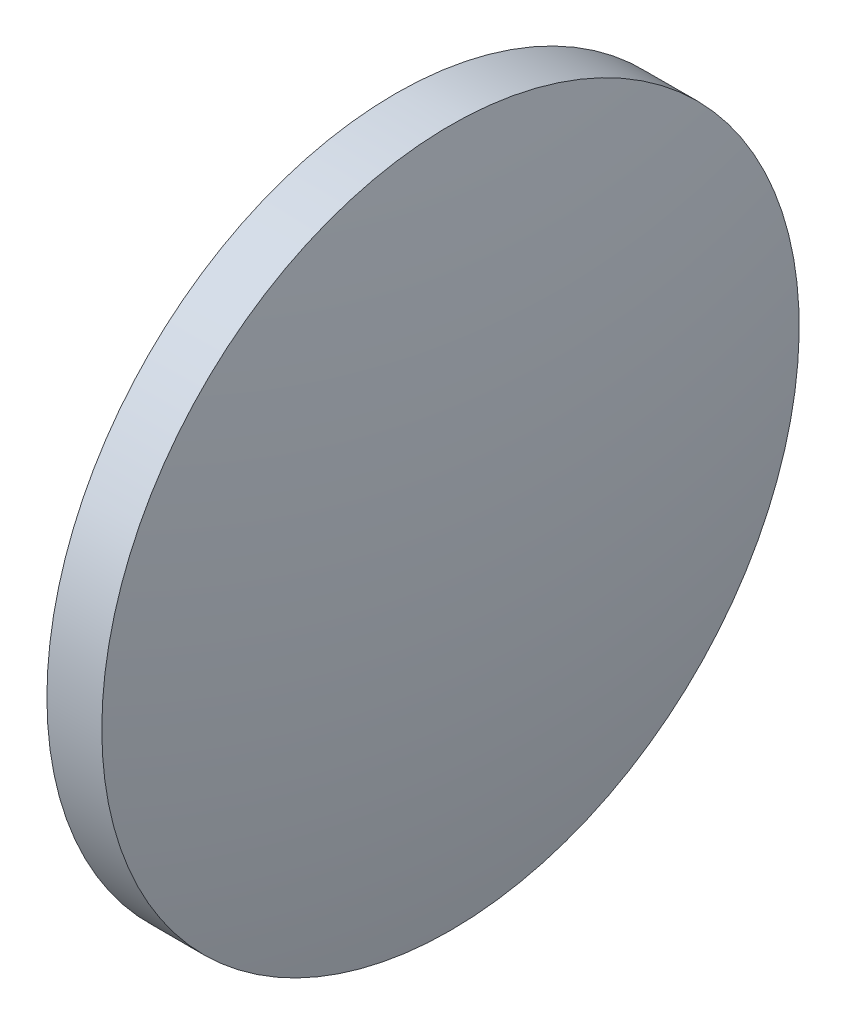
from build123d import *

# Parameters (mm, degrees)
SKETCH_1_ONE_SIDE_W = 1.999342857
SKETCH_1_ONE_SIDE_H = 12.7


with BuildPart() as part:
    # 草图1 one side → 旋转1 (revolve)
    with BuildSketch(Plane.XY, mode=Mode.PRIVATE) as revolve_1_sk:
        with Locations((86.458193775, 54.966113023)):
            Rectangle(SKETCH_1_ONE_SIDE_W, SKETCH_1_ONE_SIDE_H)
        with BuildLine():
            Line((84.208479489, 48.616113023), (85.458522346, 48.616113023))
            Line((85.458522346, 48.616113023), (85.458522346, 61.316113023))
            ThreePointArc((85.458522346, 61.316113023), (84.521743474, 54.996798863), (84.208479489, 48.616113023))
        make_face()
        with BuildLine():
            Line((87.457865203, 48.616113023), (88.70790806, 48.616113023))
            ThreePointArc((88.70790806, 48.616113023), (88.394644075, 54.996798863), (87.457865203, 61.316113023))
            Line((87.457865203, 61.316113023), (87.457865203, 48.616113023))
        make_face()
    revolve(revolve_1_sk.sketch.rotate(Axis((79.305401351, 48.616113023, 0), (1, 0, 0)), 90), axis=Axis((79.305401351, 48.616113023, 0), (1, 0, 0)))  # turned: the seam where the file's is


solid = part.part
